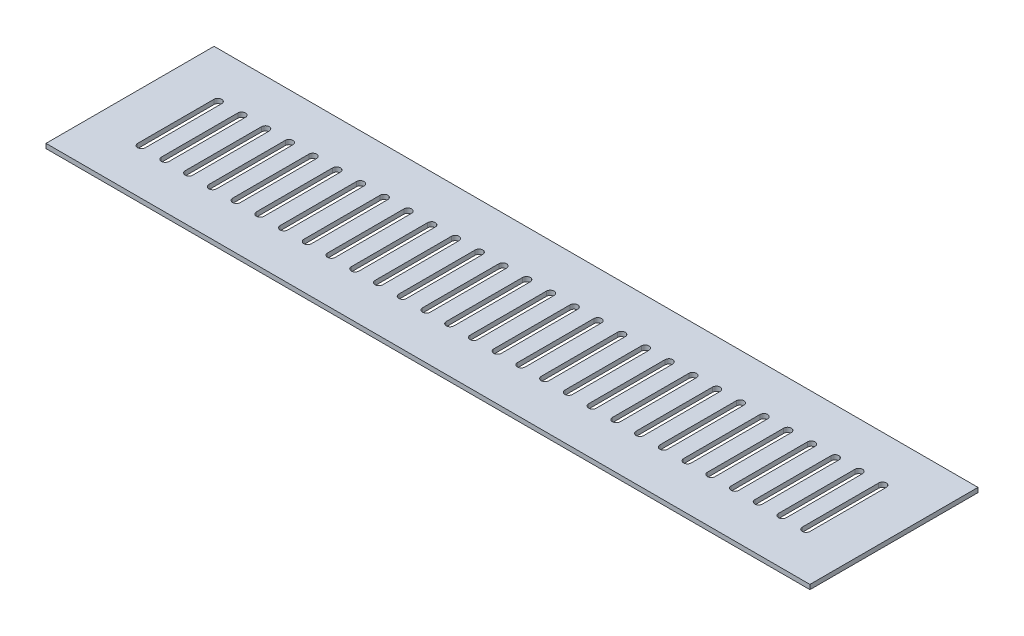
from build123d import *

# Parameters (mm, degrees)
IZIM1_W                     = 500
IZIM1_H                     = 110
Y_KSEKLIK_EKSTR_ZYON1_DEPTH = 3
KES_EKSTR_ZYON1_DEPTH       = 3


with BuildPart() as part:
    # Çizim1 → Yükseklik-Ekstrüzyon1 (new body)
    with BuildSketch(Plane(origin=(0, 0, 0), x_dir=(1, 0, 0), z_dir=(0, 1, 0))):
        with Locations((250, -55)):
            Rectangle(IZIM1_W, IZIM1_H)
    extrude(amount=Y_KSEKLIK_EKSTR_ZYON1_DEPTH)

    # Çizim2 → Kes-Ekstrüzyon1 (cut)
    with BuildSketch(Plane(origin=(0, 3, 0), x_dir=(1, 0, 0), z_dir=(0, 1, 0))):
        with BuildLine():
            Line((35, -30), (35, -80))
            ThreePointArc((35, -80), (32.5, -82.5), (30, -80))
            Line((30, -80), (30, -30))
            ThreePointArc((30, -30), (32.5, -27.5), (35, -30))
        make_face()
        with BuildLine():
            Line((45.535714286, -30), (45.535714286, -80))
            ThreePointArc((45.535714286, -80), (48.035714286, -82.5), (50.535714286, -80))
            Line((50.535714286, -80), (50.535714286, -30))
            ThreePointArc((50.535714286, -30), (48.035714286, -27.5), (45.535714286, -30))
        make_face()
        with BuildLine():
            Line((61.071428571, -30), (61.071428571, -80))
            ThreePointArc((61.071428571, -80), (63.571428571, -82.5), (66.071428571, -80))
            Line((66.071428571, -80), (66.071428571, -30))
            ThreePointArc((66.071428571, -30), (63.571428571, -27.5), (61.071428571, -30))
        make_face()
        with BuildLine():
            Line((76.607142857, -30), (76.607142857, -80))
            ThreePointArc((76.607142857, -80), (79.107142857, -82.5), (81.607142857, -80))
            Line((81.607142857, -80), (81.607142857, -30))
            ThreePointArc((81.607142857, -30), (79.107142857, -27.5), (76.607142857, -30))
        make_face()
        with BuildLine():
            Line((92.142857143, -30), (92.142857143, -80))
            ThreePointArc((92.142857143, -80), (94.642857143, -82.5), (97.142857143, -80))
            Line((97.142857143, -80), (97.142857143, -30))
            ThreePointArc((97.142857143, -30), (94.642857143, -27.5), (92.142857143, -30))
        make_face()
        with BuildLine():
            Line((107.678571429, -30), (107.678571429, -80))
            ThreePointArc((107.678571429, -80), (110.178571429, -82.5), (112.678571429, -80))
            Line((112.678571429, -80), (112.678571429, -30))
            ThreePointArc((112.678571429, -30), (110.178571429, -27.5), (107.678571429, -30))
        make_face()
        with BuildLine():
            Line((123.214285714, -30), (123.214285714, -80))
            ThreePointArc((123.214285714, -80), (125.714285714, -82.5), (128.214285714, -80))
            Line((128.214285714, -80), (128.214285714, -30))
            ThreePointArc((128.214285714, -30), (125.714285714, -27.5), (123.214285714, -30))
        make_face()
        with BuildLine():
            Line((138.75, -30), (138.75, -80))
            ThreePointArc((138.75, -80), (141.25, -82.5), (143.75, -80))
            Line((143.75, -80), (143.75, -30))
            ThreePointArc((143.75, -30), (141.25, -27.5), (138.75, -30))
        make_face()
        with BuildLine():
            Line((154.285714286, -30), (154.285714286, -80))
            ThreePointArc((154.285714286, -80), (156.785714286, -82.5), (159.285714286, -80))
            Line((159.285714286, -80), (159.285714286, -30))
            ThreePointArc((159.285714286, -30), (156.785714286, -27.5), (154.285714286, -30))
        make_face()
        with BuildLine():
            Line((169.821428571, -30), (169.821428571, -80))
            ThreePointArc((169.821428571, -80), (172.321428571, -82.5), (174.821428571, -80))
            Line((174.821428571, -80), (174.821428571, -30))
            ThreePointArc((174.821428571, -30), (172.321428571, -27.5), (169.821428571, -30))
        make_face()
        with BuildLine():
            Line((185.357142857, -30), (185.357142857, -80))
            ThreePointArc((185.357142857, -80), (187.857142857, -82.5), (190.357142857, -80))
            Line((190.357142857, -80), (190.357142857, -30))
            ThreePointArc((190.357142857, -30), (187.857142857, -27.5), (185.357142857, -30))
        make_face()
        with BuildLine():
            Line((200.892857143, -30), (200.892857143, -80))
            ThreePointArc((200.892857143, -80), (203.392857143, -82.5), (205.892857143, -80))
            Line((205.892857143, -80), (205.892857143, -30))
            ThreePointArc((205.892857143, -30), (203.392857143, -27.5), (200.892857143, -30))
        make_face()
        with BuildLine():
            Line((216.428571429, -30), (216.428571429, -80))
            ThreePointArc((216.428571429, -80), (218.928571429, -82.5), (221.428571429, -80))
            Line((221.428571429, -80), (221.428571429, -30))
            ThreePointArc((221.428571429, -30), (218.928571429, -27.5), (216.428571429, -30))
        make_face()
        with BuildLine():
            Line((231.964285714, -30), (231.964285714, -80))
            ThreePointArc((231.964285714, -80), (234.464285714, -82.5), (236.964285714, -80))
            Line((236.964285714, -80), (236.964285714, -30))
            ThreePointArc((236.964285714, -30), (234.464285714, -27.5), (231.964285714, -30))
        make_face()
        with BuildLine():
            Line((247.5, -30), (247.5, -80))
            ThreePointArc((247.5, -80), (250, -82.5), (252.5, -80))
            Line((252.5, -80), (252.5, -30))
            ThreePointArc((252.5, -30), (250, -27.5), (247.5, -30))
        make_face()
        with BuildLine():
            Line((263.035714286, -30), (263.035714286, -80))
            ThreePointArc((263.035714286, -80), (265.535714286, -82.5), (268.035714286, -80))
            Line((268.035714286, -80), (268.035714286, -30))
            ThreePointArc((268.035714286, -30), (265.535714286, -27.5), (263.035714286, -30))
        make_face()
        with BuildLine():
            Line((278.571428571, -30), (278.571428571, -80))
            ThreePointArc((278.571428571, -80), (281.071428571, -82.5), (283.571428571, -80))
            Line((283.571428571, -80), (283.571428571, -30))
            ThreePointArc((283.571428571, -30), (281.071428571, -27.5), (278.571428571, -30))
        make_face()
        with BuildLine():
            Line((294.107142857, -30), (294.107142857, -80))
            ThreePointArc((294.107142857, -80), (296.607142857, -82.5), (299.107142857, -80))
            Line((299.107142857, -80), (299.107142857, -30))
            ThreePointArc((299.107142857, -30), (296.607142857, -27.5), (294.107142857, -30))
        make_face()
        with BuildLine():
            Line((309.642857143, -30), (309.642857143, -80))
            ThreePointArc((309.642857143, -80), (312.142857143, -82.5), (314.642857143, -80))
            Line((314.642857143, -80), (314.642857143, -30))
            ThreePointArc((314.642857143, -30), (312.142857143, -27.5), (309.642857143, -30))
        make_face()
        with BuildLine():
            Line((325.178571429, -30), (325.178571429, -80))
            ThreePointArc((325.178571429, -80), (327.678571429, -82.5), (330.178571429, -80))
            Line((330.178571429, -80), (330.178571429, -30))
            ThreePointArc((330.178571429, -30), (327.678571429, -27.5), (325.178571429, -30))
        make_face()
        with BuildLine():
            Line((340.714285714, -30), (340.714285714, -80))
            ThreePointArc((340.714285714, -80), (343.214285714, -82.5), (345.714285714, -80))
            Line((345.714285714, -80), (345.714285714, -30))
            ThreePointArc((345.714285714, -30), (343.214285714, -27.5), (340.714285714, -30))
        make_face()
        with BuildLine():
            Line((356.25, -30), (356.25, -80))
            ThreePointArc((356.25, -80), (358.75, -82.5), (361.25, -80))
            Line((361.25, -80), (361.25, -30))
            ThreePointArc((361.25, -30), (358.75, -27.5), (356.25, -30))
        make_face()
        with BuildLine():
            Line((371.785714286, -30), (371.785714286, -80))
            ThreePointArc((371.785714286, -80), (374.285714286, -82.5), (376.785714286, -80))
            Line((376.785714286, -80), (376.785714286, -30))
            ThreePointArc((376.785714286, -30), (374.285714286, -27.5), (371.785714286, -30))
        make_face()
        with BuildLine():
            Line((387.321428571, -30), (387.321428571, -80))
            ThreePointArc((387.321428571, -80), (389.821428571, -82.5), (392.321428571, -80))
            Line((392.321428571, -80), (392.321428571, -30))
            ThreePointArc((392.321428571, -30), (389.821428571, -27.5), (387.321428571, -30))
        make_face()
        with BuildLine():
            Line((402.857142857, -30), (402.857142857, -80))
            ThreePointArc((402.857142857, -80), (405.357142857, -82.5), (407.857142857, -80))
            Line((407.857142857, -80), (407.857142857, -30))
            ThreePointArc((407.857142857, -30), (405.357142857, -27.5), (402.857142857, -30))
        make_face()
        with BuildLine():
            Line((418.392857143, -30), (418.392857143, -80))
            ThreePointArc((418.392857143, -80), (420.892857143, -82.5), (423.392857143, -80))
            Line((423.392857143, -80), (423.392857143, -30))
            ThreePointArc((423.392857143, -30), (420.892857143, -27.5), (418.392857143, -30))
        make_face()
        with BuildLine():
            Line((433.928571429, -30), (433.928571429, -80))
            ThreePointArc((433.928571429, -80), (436.428571429, -82.5), (438.928571429, -80))
            Line((438.928571429, -80), (438.928571429, -30))
            ThreePointArc((438.928571429, -30), (436.428571429, -27.5), (433.928571429, -30))
        make_face()
        with BuildLine():
            Line((449.464285714, -30), (449.464285714, -80))
            ThreePointArc((449.464285714, -80), (451.964285714, -82.5), (454.464285714, -80))
            Line((454.464285714, -80), (454.464285714, -30))
            ThreePointArc((454.464285714, -30), (451.964285714, -27.5), (449.464285714, -30))
        make_face()
        with BuildLine():
            Line((465, -30), (465, -80))
            ThreePointArc((465, -80), (467.5, -82.5), (470, -80))
            Line((470, -80), (470, -30))
            ThreePointArc((470, -30), (467.5, -27.5), (465, -30))
        make_face()
    extrude(amount=-KES_EKSTR_ZYON1_DEPTH, mode=Mode.SUBTRACT)


solid = part.part
